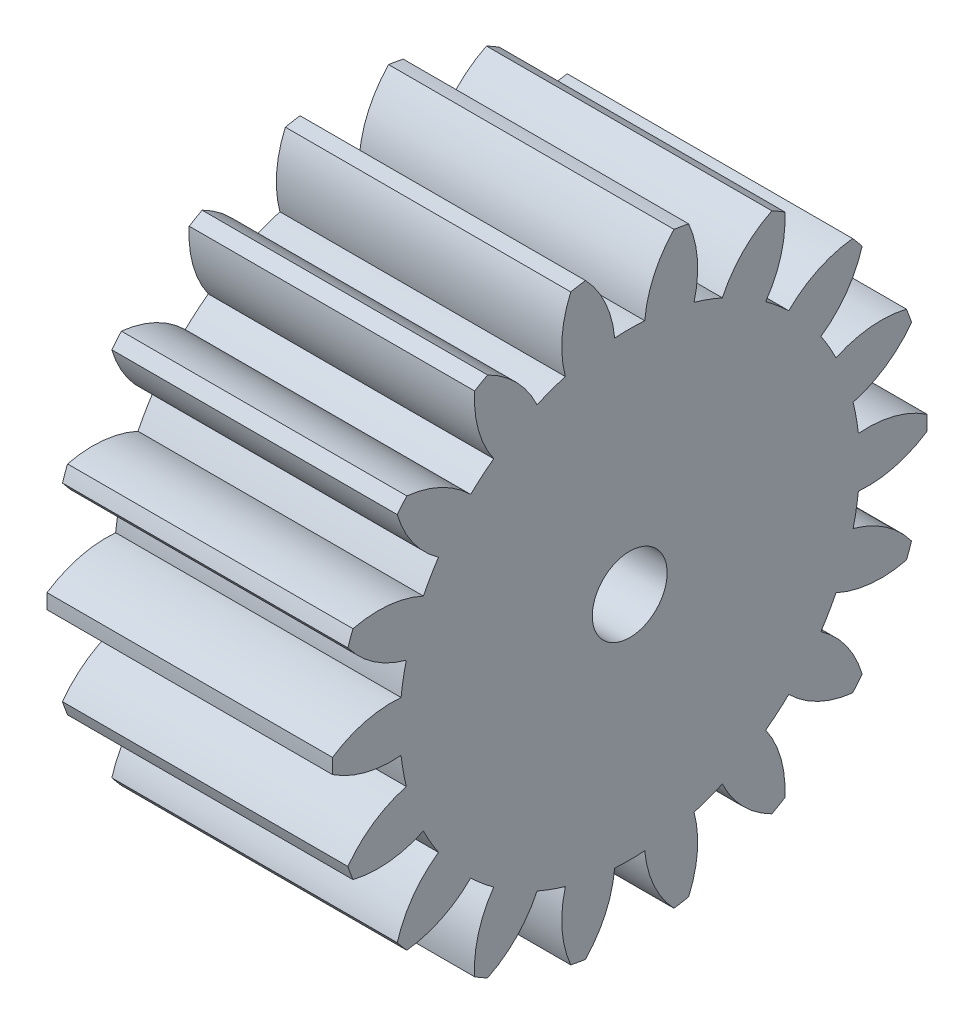
from build123d import *

# Parameters (mm, degrees)
BASPROSKE_W     = 7.62
BASPROSKE_H     = 7.9375
TOOTHCUT_DEPTH  = 14.567321493
TEETHCUTS_COUNT = 18
TEETHCUTS_ANGLE = 340
BORSKE_R        = 0.99949
BORE_DEPTH      = 50.8000508


with BuildPart() as part:
    # BasProSke → Base-Revolve (revolve)
    with BuildSketch(Plane(origin=(0, 0, 0), x_dir=(1, 0, 0), z_dir=(0, 1, 0)), mode=Mode.PRIVATE) as base_revolve_sk:
        with Locations((3.81, 3.96875)):
            Rectangle(BASPROSKE_W, BASPROSKE_H)
    revolve(base_revolve_sk.sketch.rotate(Axis((-10, 0, 0), (1, 0, 0)), 180), axis=Axis((-10, 0, 0), (1, 0, 0)))

    # TooCutSke → ToothCut (cut, through all)
    with BuildSketch(Plane(origin=(0, 0, 0), x_dir=(0, 0, -1), z_dir=(1, 0, 0))):
        with BuildLine():
            ThreePointArc((0.401805019, 6.127289689), (0, 6.14045), (-0.401805019, 6.127289689))
            ThreePointArc((-0.401805019, 6.127289689), (-0.651999955, 7.068698885), (-1.203877601, 7.87136933))
            ThreePointArc((-1.203877601, 7.87136933), (0, 7.9629), (1.203877601, 7.87136933))
            ThreePointArc((1.203877601, 7.87136933), (0.651999955, 7.068698885), (0.401805019, 6.127289689))
        make_face()
    toothcut = extrude(amount=TOOTHCUT_DEPTH, mode=Mode.SUBTRACT)

    # TeethCuts: ToothCut ×18 about axis
    teethcuts_axis = Axis((-10, 0, 0), (1, 0, 0))
    for i in range(1, TEETHCUTS_COUNT):
        add(toothcut.rotate(teethcuts_axis, i * TEETHCUTS_ANGLE / (TEETHCUTS_COUNT - 1)), mode=Mode.SUBTRACT)

    # BorSke → Bore (cut, symmetric)
    with BuildSketch(Plane(origin=(0, 0, 0), x_dir=(0, 0, -1), z_dir=(1, 0, 0))):
        with Locations(Location((0, 0, 0), (0, 0, 180))):
            Circle(BORSKE_R)
    extrude(amount=BORE_DEPTH, both=True, mode=Mode.SUBTRACT)


solid = part.part
